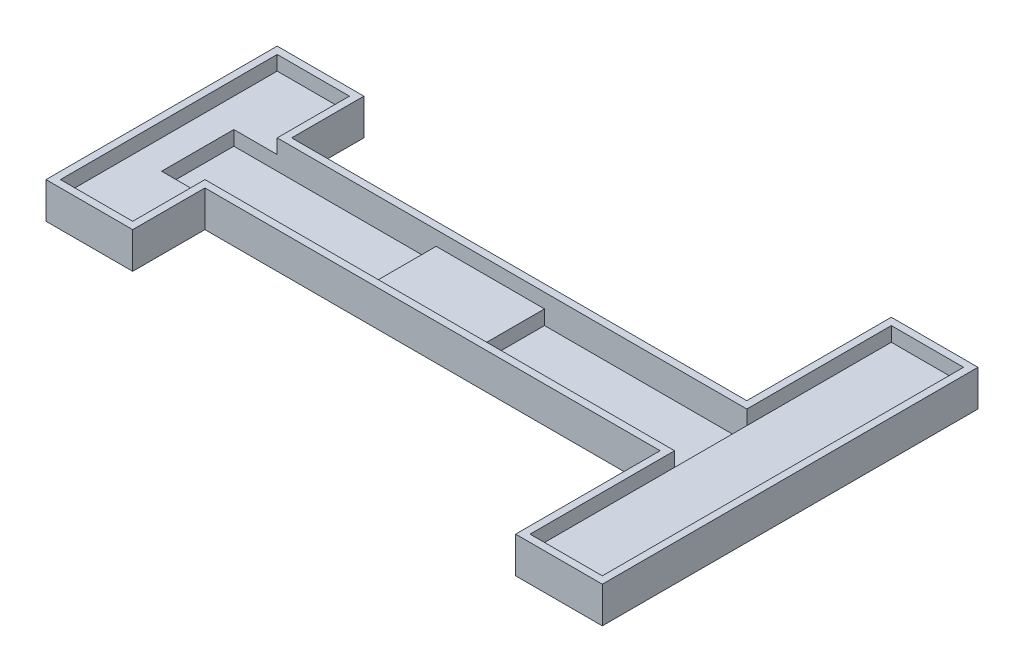
from build123d import *

# Parameters (mm, degrees)
SKETCH_2_W           = 65
SKETCH_2_H           = 10
SKETCH_2_W_2         = 6
EXTRUDE_1_DEPTH      = 1
EXTRUDE_2_DEPTH      = 4
EXTRUDE_2_DEPTH_BACK = 1
SKETCH_5_W           = 15
SKETCH_5_H           = 10
SKETCH_5_W_2         = 10
SKETCH_5_H_2         = 50
EXTRUDE_3_DEPTH      = 2


with BuildPart() as part:
    # 草图2 → 凸台-拉伸1 (new body)
    with BuildSketch(Plane(origin=(0, 0, 0), x_dir=(1, 0, 0), z_dir=(0, 1, 0))):
        with Locations((-18.5, 0)):
            Rectangle(SKETCH_2_W, SKETCH_2_H)
        with Locations((-54, 0)):
            Rectangle(SKETCH_2_W_2, SKETCH_2_H)
        Polygon((-51, 15), (-61, 15), (-61, -15), (-51, -15), (-51, -5), (-57, -5), (-57, 5), (-51, 5), align=None)
        Polygon((14, 25), (14, 5), (14, -5), (14, -25), (24, -25), (24, 25), align=None)
    extrude(amount=EXTRUDE_1_DEPTH)

    # 草图4 → 凸台-拉伸2 (add, two sides)
    with BuildSketch(Plane(origin=(0, 1, 0), x_dir=(1, 0, 0), z_dir=(0, 1, 0))) as extrude_2_sk:
        Polygon((-50, -16), (-50, -6), (13, -6), (13, -26), (25, -26), (25, 26), (13, 26), (13, 6), (-50, 6), (-50, 16), (-62, 16), (-62, -16), align=None)
        Polygon((-51, -15), (-51, -5), (14, -5), (14, -25), (24, -25), (24, 25), (14, 25), (14, 5), (-51, 5), (-51, 15), (-61, 15), (-61, -15), align=None, mode=Mode.SUBTRACT)
    extrude(amount=EXTRUDE_2_DEPTH)
    extrude(extrude_2_sk.sketch, amount=-EXTRUDE_2_DEPTH_BACK)

    # 草图5 → 凸台-拉伸3 (add)
    with BuildSketch(Plane(origin=(0, 1, 0), x_dir=(1, 0, 0), z_dir=(0, 1, 0))):
        Polygon((-57, 5), (-57, -5), (-51, -5), (-51, -15), (-61, -15), (-61, 15), (-51, 15), (-51, 5), align=None)
        with Locations((-21.5, 0)):
            Rectangle(SKETCH_5_W, SKETCH_5_H)
        with Locations((19, 0)):
            Rectangle(SKETCH_5_W_2, SKETCH_5_H_2)
    extrude(amount=EXTRUDE_3_DEPTH)


solid = part.part
